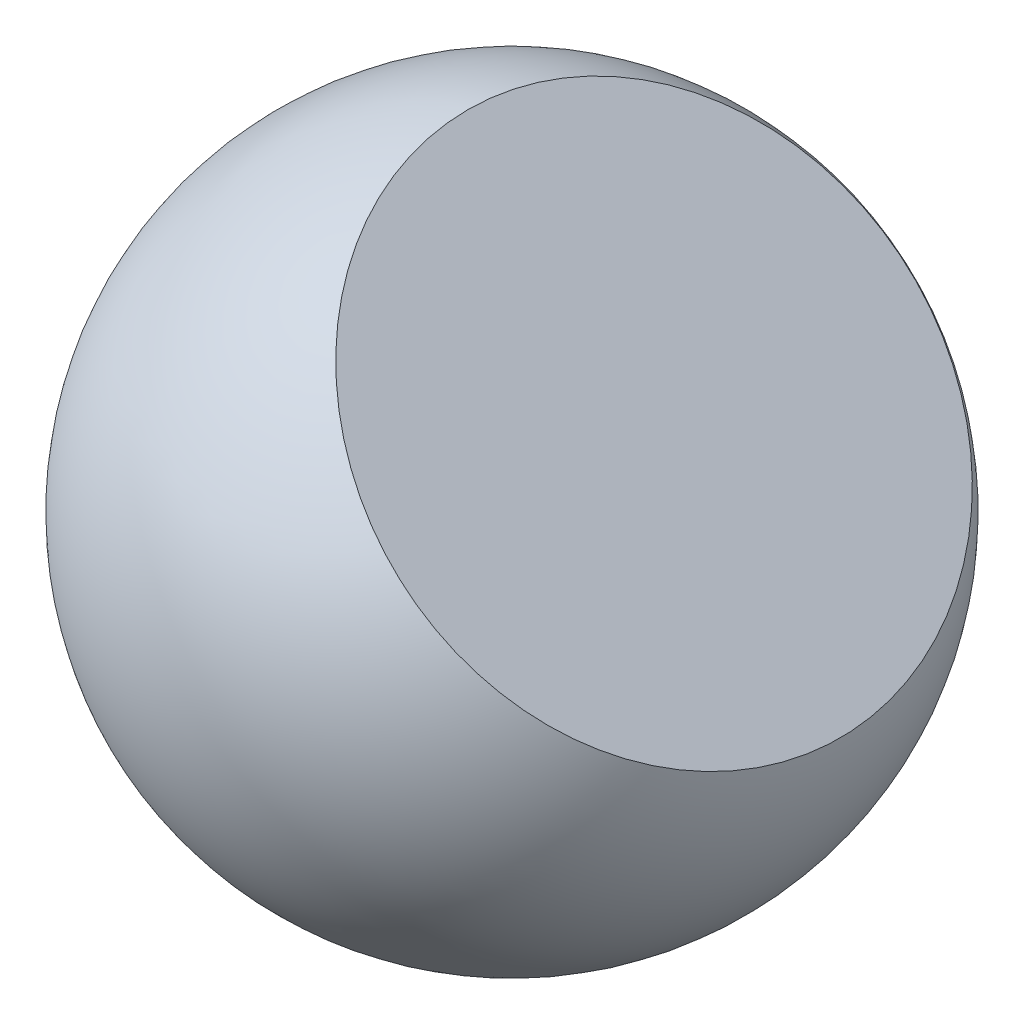
from build123d import *


with BuildPart() as part:
    # Sketch2 → Revolve1 (revolve)
    with BuildSketch(Plane(origin=(0, 0, 0), x_dir=(1, 0, 0), z_dir=(0, 1, 0))):
        with BuildLine():
            Line((-381, 0), (381, 0))
            ThreePointArc((381, 0), (0, 381), (-381, 0))
        make_face()
    revolve(axis=Axis((-381, 0, 0), (1, 0, 0)))

    # SurfaceCut1
    split(bisect_by=Plane(origin=(164.227634794, 170.588907734, 0), x_dir=(-0.720411288, 0.693547098, 0), z_dir=(0.693547098, 0.720411288, 0)), keep=Keep.BOTTOM)


solid = part.part
